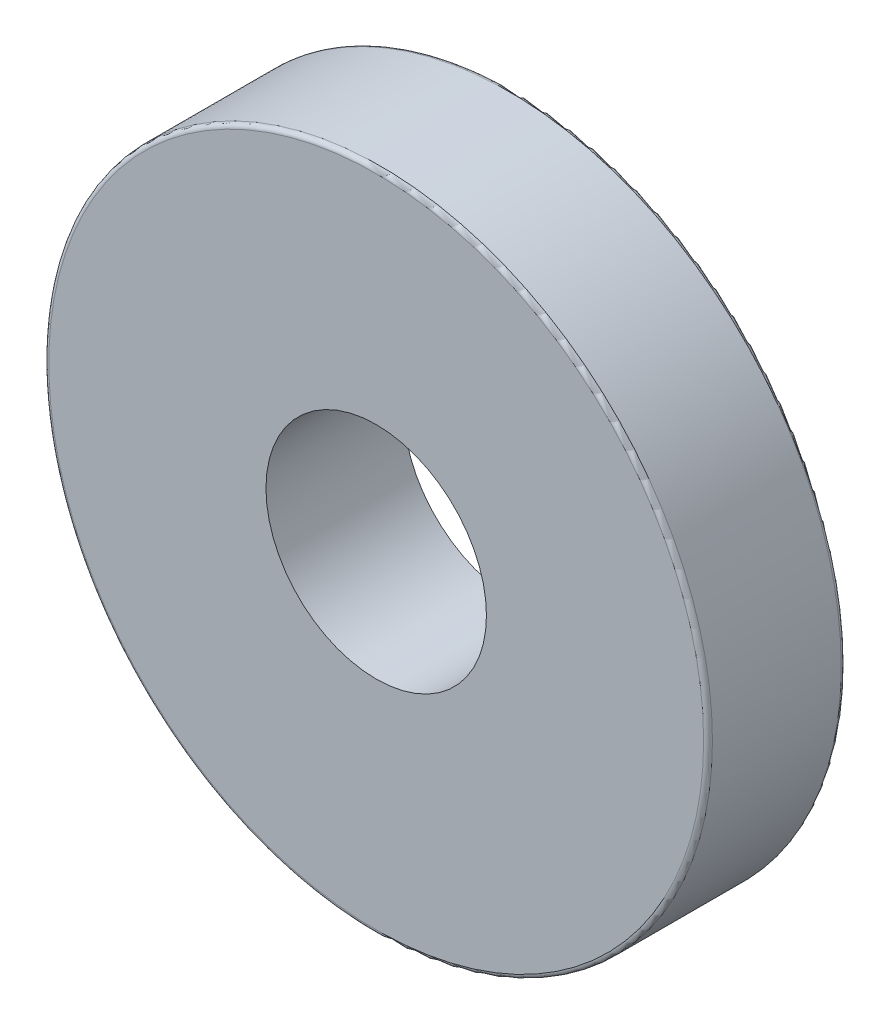
from build123d import *


with BuildPart() as part:
    # Sketch1 → Revolve1 (revolve)
    with BuildSketch(Plane(origin=(0, 0, 0), x_dir=(1, 0, 0), z_dir=(0, 1, 0))):
        with BuildLine():
            Line((1.143, 0), (10.525125, 0))
            ThreePointArc((10.525125, 0), (10.659828842, 0.055796158), (10.715625, 0.1905))
            Line((10.715625, 0.1905), (10.715625, 5.7531))
            ThreePointArc((10.715625, 5.7531), (10.659828842, 5.887803842), (10.525125, 5.9436))
            Line((10.525125, 5.9436), (1.143, 5.9436))
            Line((1.143, 5.9436), (1.143, 0))
        make_face()
    revolve(axis=Axis((-3.6195, 0, -5.9436), (0, 0, 1)))


solid = part.part
